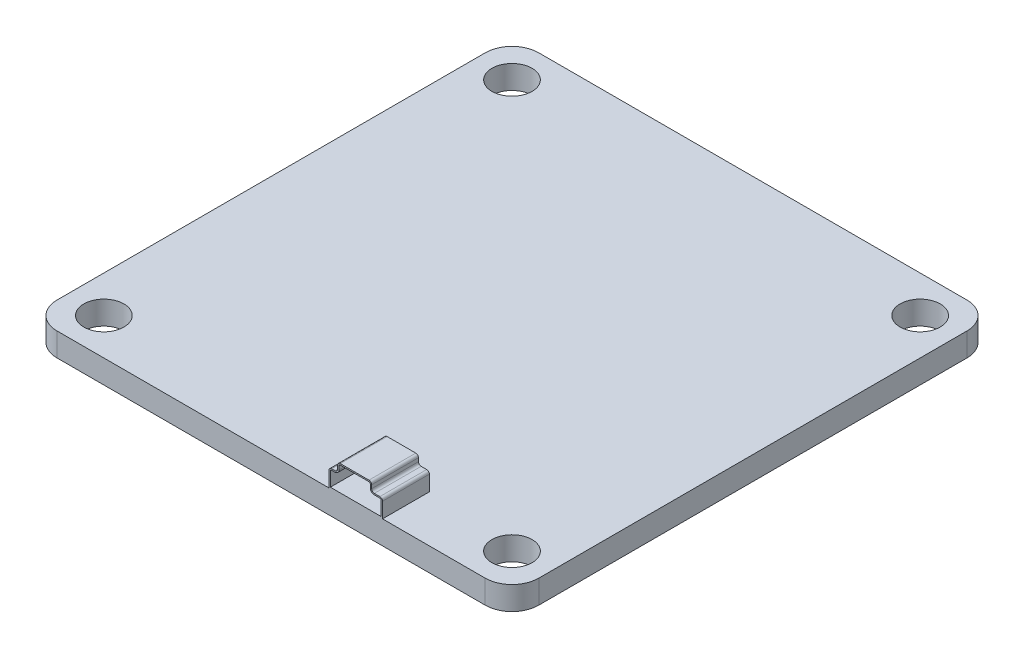
from build123d import *

# Parameters (mm, degrees)
SKETCH1_R           = 1.5
BOSS_EXTRUDE1_DEPTH = 1.75
BOSS_EXTRUDE2_DEPTH = 3
BOSS_EXTRUDE3_DEPTH = 0.5
CUT_EXTRUDE1_REACH  = 5.5
SKETCH4_R           = 0.25


with BuildPart() as part:
    # Sketch1 → Boss-Extrude1 (new body)
    with BuildSketch(Plane(origin=(0, 0, 0), x_dir=(1, 0, 0), z_dir=(0, 1, 0))):
        with BuildLine():
            Line((16, -18), (-16, -18))
            ThreePointArc((-16, -18), (-17.414213562, -17.414213562), (-18, -16))
            Line((-18, -16), (-18, 16))
            ThreePointArc((-18, 16), (-17.414213562, 17.414213562), (-16, 18))
            Line((-16, 18), (16, 18))
            ThreePointArc((16, 18), (17.414213562, 17.414213562), (18, 16))
            Line((18, 16), (18, -16))
            ThreePointArc((18, -16), (17.414213562, -17.414213562), (16, -18))
        make_face()
        with Locations((-15.25, 15.25)):
            Circle(SKETCH1_R, mode=Mode.SUBTRACT)
        with Locations((15.25, 15.25)):
            Circle(SKETCH1_R, mode=Mode.SUBTRACT)
        with Locations((15.25, -15.25)):
            Circle(SKETCH1_R, mode=Mode.SUBTRACT)
        with Locations((-15.25, -15.25)):
            Circle(SKETCH1_R, mode=Mode.SUBTRACT)
    extrude(amount=BOSS_EXTRUDE1_DEPTH)

    # Sketch2 → Boss-Extrude2 (add)
    with BuildSketch(Plane.XY.offset(18)):
        with BuildLine():
            Line((4.325932744, 1.75), (8.325932744, 1.75))
            Line((8.325932744, 1.75), (8.325932744, 2.893191045))
            ThreePointArc((8.325932744, 2.893191045), (8.2673541, 3.034612401), (8.125932744, 3.093191045))
            Line((8.125932744, 3.093191045), (7.710555572, 3.093191045))
            ThreePointArc((7.710555572, 3.093191045), (7.569134216, 3.151769689), (7.510555572, 3.293191045))
            Line((7.510555572, 3.293191045), (7.510555572, 3.55))
            ThreePointArc((7.510555572, 3.55), (7.451976928, 3.691421356), (7.310555572, 3.75))
            Line((7.310555572, 3.75), (5.170220599, 3.75))
            ThreePointArc((5.170220599, 3.75), (5.028799243, 3.691421356), (4.970220599, 3.55))
            Line((4.970220599, 3.55), (4.970220599, 3.293191045))
            ThreePointArc((4.970220599, 3.293191045), (4.911641955, 3.151769689), (4.770220599, 3.093191045))
            Line((4.770220599, 3.093191045), (4.525932744, 3.093191045))
            ThreePointArc((4.525932744, 3.093191045), (4.384511387, 3.034612401), (4.325932744, 2.893191045))
            Line((4.325932744, 2.893191045), (4.325932744, 1.75))
        make_face()
        with BuildLine():
            Line((4.425932744, 1.85), (8.225932744, 1.85))
            Line((8.225932744, 1.85), (8.225932744, 2.893191045))
            ThreePointArc((8.225932744, 2.893191045), (8.196643422, 2.963901723), (8.125932744, 2.993191045))
            Line((8.125932744, 2.993191045), (7.710555572, 2.993191045))
            ThreePointArc((7.710555572, 2.993191045), (7.498423538, 3.081059011), (7.410555572, 3.293191045))
            Line((7.410555572, 3.293191045), (7.410555572, 3.55))
            ThreePointArc((7.410555572, 3.55), (7.38126625, 3.620710678), (7.310555572, 3.65))
            Line((7.310555572, 3.65), (5.170220599, 3.65))
            ThreePointArc((5.170220599, 3.65), (5.099509921, 3.620710678), (5.070220599, 3.55))
            Line((5.070220599, 3.55), (5.070220599, 3.293191045))
            ThreePointArc((5.070220599, 3.293191045), (4.982352633, 3.081059011), (4.770220599, 2.993191045))
            Line((4.770220599, 2.993191045), (4.525932744, 2.993191045))
            ThreePointArc((4.525932744, 2.993191045), (4.455222065, 2.963901723), (4.425932744, 2.893191045))
            Line((4.425932744, 2.893191045), (4.425932744, 1.85))
        make_face(mode=Mode.SUBTRACT)
    extrude(amount=-BOSS_EXTRUDE2_DEPTH)

    # Sketch3 → Boss-Extrude3 (add)
    with BuildSketch(Plane(origin=(0, 0, 15), x_dir=(-1, 0, 0), z_dir=(0, 0, -1))):
        with BuildLine():
            Line((-4.325932744, 1.75), (-4.325932744, 2.893191045))
            ThreePointArc((-4.325932744, 2.893191045), (-4.384511387, 3.034612401), (-4.525932744, 3.093191045))
            Line((-4.525932744, 3.093191045), (-4.770220599, 3.093191045))
            ThreePointArc((-4.770220599, 3.093191045), (-4.911641955, 3.151769689), (-4.970220599, 3.293191045))
            Line((-4.970220599, 3.293191045), (-4.970220599, 3.55))
            ThreePointArc((-4.970220599, 3.55), (-5.028799243, 3.691421356), (-5.170220599, 3.75))
            Line((-5.170220599, 3.75), (-7.310555572, 3.75))
            ThreePointArc((-7.310555572, 3.75), (-7.451976928, 3.691421356), (-7.510555572, 3.55))
            Line((-7.510555572, 3.55), (-7.510555572, 3.293191045))
            ThreePointArc((-7.510555572, 3.293191045), (-7.569134216, 3.151769689), (-7.710555572, 3.093191045))
            Line((-7.710555572, 3.093191045), (-8.125932744, 3.093191045))
            ThreePointArc((-8.125932744, 3.093191045), (-8.2673541, 3.034612401), (-8.325932744, 2.893191045))
            Line((-8.325932744, 2.893191045), (-8.325932744, 1.75))
            Line((-8.325932744, 1.75), (-4.325932744, 1.75))
        make_face()
    extrude(amount=BOSS_EXTRUDE3_DEPTH)

    # Sketch4 → Cut-Extrude1 (cut, up to next)
    with BuildSketch(Plane(origin=(0, 0, 14.5), x_dir=(-1, 0, 0), z_dir=(0, 0, -1)), mode=Mode.PRIVATE) as cut_extrude1_sk1:
        with Locations((-7.325932744, 2.817782328)):
            Circle(SKETCH4_R)
    cut_extrude1_tool1 = extrude(cut_extrude1_sk1.sketch, amount=-CUT_EXTRUDE1_REACH, mode=Mode.PRIVATE) & part.part
    add(cut_extrude1_tool1.solids().sort_by_distance((7.325933, 2.817782, 14.5))[0], mode=Mode.SUBTRACT)
    # Sketch4 → Cut-Extrude1 (cut, up to next)
    with BuildSketch(Plane(origin=(0, 0, 14.5), x_dir=(-1, 0, 0), z_dir=(0, 0, -1)), mode=Mode.PRIVATE) as cut_extrude1_sk2:
        with Locations((-6.325932744, 2.817782328)):
            Circle(SKETCH4_R)
    cut_extrude1_tool2 = extrude(cut_extrude1_sk2.sketch, amount=-CUT_EXTRUDE1_REACH, mode=Mode.PRIVATE) & part.part
    add(cut_extrude1_tool2.solids().sort_by_distance((6.325933, 2.817782, 14.5))[0], mode=Mode.SUBTRACT)
    # Sketch4 → Cut-Extrude1 (cut, up to next)
    with BuildSketch(Plane(origin=(0, 0, 14.5), x_dir=(-1, 0, 0), z_dir=(0, 0, -1)), mode=Mode.PRIVATE) as cut_extrude1_sk3:
        with Locations((-5.325932744, 2.817782328)):
            Circle(SKETCH4_R)
    cut_extrude1_tool3 = extrude(cut_extrude1_sk3.sketch, amount=-CUT_EXTRUDE1_REACH, mode=Mode.PRIVATE) & part.part
    add(cut_extrude1_tool3.solids().sort_by_distance((5.325933, 2.817782, 14.5))[0], mode=Mode.SUBTRACT)


solid = part.part
